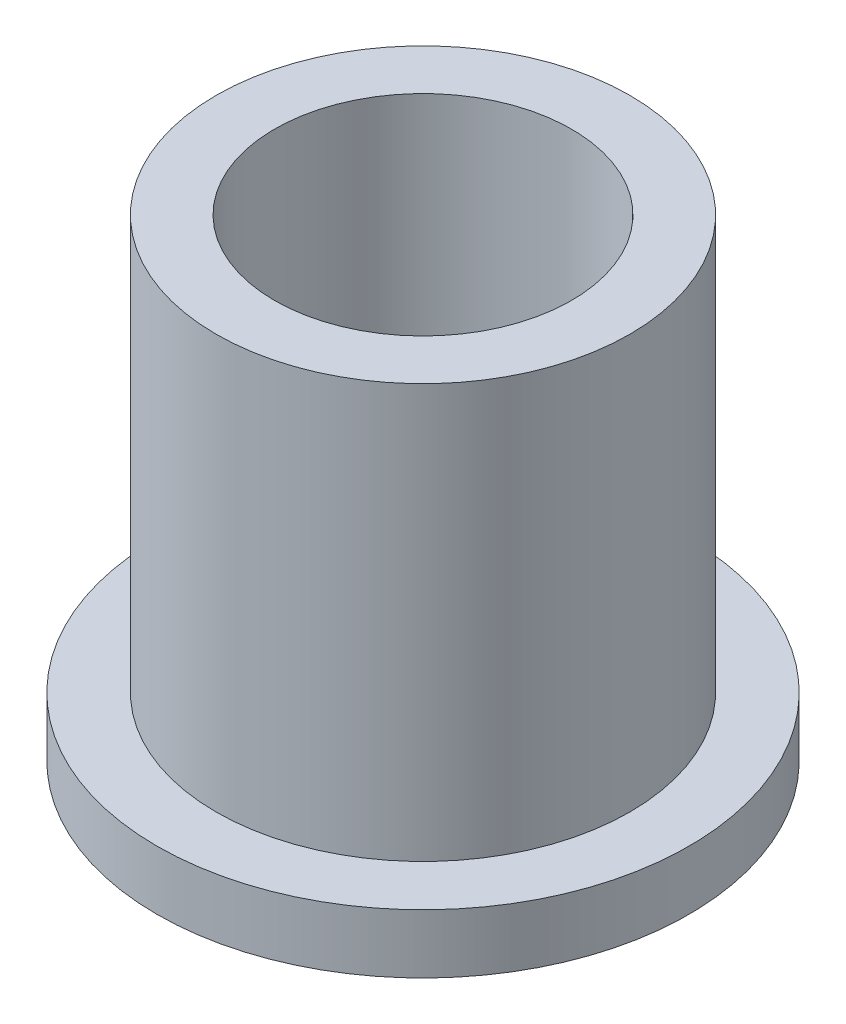
from build123d import *

# Parameters (mm, degrees)
SKETCH2_R           = 5.55625
SKETCH2_R_2         = 3.9878
BOSS_EXTRUDE1_DEPTH = 12.7
SKETCH3_R           = 7.14375
SKETCH3_R_2         = 5.55625
BOSS_EXTRUDE2_DEPTH = 1.5875


with BuildPart() as part:
    # Sketch2 → Boss-Extrude1 (new body)
    with BuildSketch(Plane(origin=(0, 0, 0), x_dir=(1, 0, 0), z_dir=(0, 1, 0))):
        Circle(SKETCH2_R)
        Circle(SKETCH2_R_2, mode=Mode.SUBTRACT)
    extrude(amount=BOSS_EXTRUDE1_DEPTH)

    # Sketch3 → Boss-Extrude2 (add)
    with BuildSketch(Plane(origin=(0, 0, 0), x_dir=(1, 0, 0), z_dir=(0, 1, 0))):
        Circle(SKETCH3_R)
        Circle(SKETCH3_R_2, mode=Mode.SUBTRACT)
    extrude(amount=BOSS_EXTRUDE2_DEPTH)


solid = part.part
